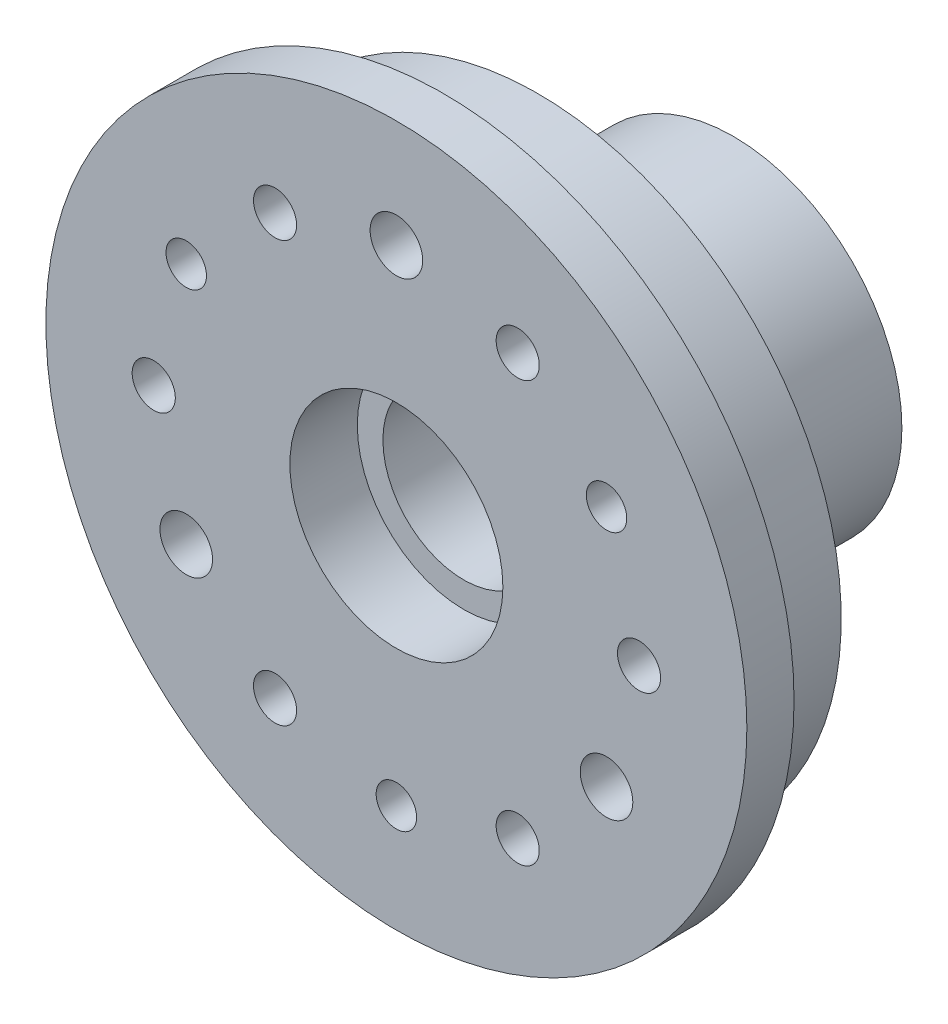
from build123d import *

# Parameters (mm, degrees)
SKETCH1_R           = 25
BOSS_EXTRUDE1_DEPTH = 20
SKETCH2_R           = 1.95
CUT_EXTRUDE1_DEPTH  = 4
SKETCH4_R           = 1.5
CUT_EXTRUDE2_DEPTH  = 21
SKETCH6_R           = 7.9
CUT_EXTRUDE3_DEPTH  = 21
BOSS_EXTRUDE4_START = -6
SKETCH7_R           = 7.9
SKETCH7_R_2         = 6
BOSS_EXTRUDE4_DEPTH = 9
SKETCH9_R           = 26
SKETCH9_R_2         = 25
BOSS_EXTRUDE6_DEPTH = 3.5
SKETCH10_R          = 25
SKETCH10_R_2        = 22.5
CUT_EXTRUDE5_DEPTH  = 16.5
SKETCH11_R          = 22.5
SKETCH11_R_2        = 12.5
CUT_EXTRUDE6_DEPTH  = 9.5
SKETCH12_R          = 3
CUT_EXTRUDE7_DEPTH  = 5
CIRPATTERN2_COUNT   = 3
SKETCH13_R          = 1.6
CUT_EXTRUDE8_DEPTH  = 21
CIRPATTERN3_COUNT   = 6
SKETCH15_R          = 12.5
SKETCH15_R_2        = 7.9
BOSS_EXTRUDE7_DEPTH = 5


with BuildPart() as part:
    # Sketch1 → Boss-Extrude1 (new body)
    with BuildSketch(Plane.XY):
        Circle(SKETCH1_R)
    extrude(amount=BOSS_EXTRUDE1_DEPTH)

    # Sketch2 → Cut-Extrude1 (cut)
    with BuildSketch(Plane.XY.offset(20)):
        with Locations((0, 18)):
            Circle(SKETCH2_R)
        with Locations((15.588457268, -9)):
            Circle(SKETCH2_R)
        with Locations((-15.588457268, -9)):
            Circle(SKETCH2_R)
    extrude(amount=-CUT_EXTRUDE1_DEPTH, mode=Mode.SUBTRACT)

    # Sketch4 → Cut-Extrude2 (cut, through all)
    with BuildSketch(Plane.XY.offset(20)):
        with Locations((15.588457268, 9)):
            Circle(SKETCH4_R)
        with Locations((0, -18)):
            Circle(SKETCH4_R)
        with Locations((-15.588457268, 9)):
            Circle(SKETCH4_R)
    extrude(amount=-CUT_EXTRUDE2_DEPTH, mode=Mode.SUBTRACT)

    # Sketch6 → Cut-Extrude3 (cut, through all)
    with BuildSketch(Plane.XY.offset(20)):
        Circle(SKETCH6_R)
    extrude(amount=-CUT_EXTRUDE3_DEPTH, mode=Mode.SUBTRACT)

    # Sketch7 → Boss-Extrude4 (add)
    with BuildSketch(Plane(origin=(0, 0, 0), x_dir=(-1, 0, 0), z_dir=(0, 0, -1)).offset(BOSS_EXTRUDE4_START)):
        Circle(SKETCH7_R)
        Circle(SKETCH7_R_2, mode=Mode.SUBTRACT)
    extrude(amount=-BOSS_EXTRUDE4_DEPTH)

    # Sketch9 → Boss-Extrude6 (add)
    with BuildSketch(Plane.XY.offset(20)):
        Circle(SKETCH9_R)
        Circle(SKETCH9_R_2, mode=Mode.SUBTRACT)
    extrude(amount=-BOSS_EXTRUDE6_DEPTH)

    # Sketch10 → Cut-Extrude5 (cut)
    with BuildSketch(Plane(origin=(0, 0, 0), x_dir=(-1, 0, 0), z_dir=(0, 0, -1))):
        Circle(SKETCH10_R)
        Circle(SKETCH10_R_2, mode=Mode.SUBTRACT)
    extrude(amount=-CUT_EXTRUDE5_DEPTH, mode=Mode.SUBTRACT)

    # Sketch11 → Cut-Extrude6 (cut)
    with BuildSketch(Plane(origin=(0, 0, 0), x_dir=(-1, 0, 0), z_dir=(0, 0, -1))):
        Circle(SKETCH11_R)
        Circle(SKETCH11_R_2, mode=Mode.SUBTRACT)
    extrude(amount=-CUT_EXTRUDE6_DEPTH, mode=Mode.SUBTRACT)

    # Sketch12 → Cut-Extrude7 (cut)
    with BuildSketch(Plane(origin=(0, 0, 9.5), x_dir=(-1, 0, 0), z_dir=(0, 0, -1))):
        with Locations((-15.588457268, 9)):
            Circle(SKETCH12_R)
    cut_extrude7 = extrude(amount=-CUT_EXTRUDE7_DEPTH, mode=Mode.SUBTRACT)

    # CirPattern2: Cut-Extrude7 ×3 about axis
    cirpattern2_axis = Axis((0, 0, 0), (0, 0, 1))
    for i in range(1, CIRPATTERN2_COUNT):
        add(cut_extrude7.rotate(cirpattern2_axis, i * 360 / CIRPATTERN2_COUNT), mode=Mode.SUBTRACT)

    # Sketch13 → Cut-Extrude8 (cut, through all)
    with BuildSketch(Plane.XY.offset(20)):
        with Locations((-9, 15.588457268)):
            Circle(SKETCH13_R)
    cut_extrude8 = extrude(amount=-CUT_EXTRUDE8_DEPTH, mode=Mode.SUBTRACT)

    # CirPattern3: Cut-Extrude8 ×6 about axis
    cirpattern3_axis = Axis((0, 0, 0), (0, 0, 1))
    for i in range(1, CIRPATTERN3_COUNT):
        add(cut_extrude8.rotate(cirpattern3_axis, i * 360 / CIRPATTERN3_COUNT), mode=Mode.SUBTRACT)

    # Sketch15 → Boss-Extrude7 (add)
    with BuildSketch(Plane(origin=(0, 0, 0), x_dir=(-1, 0, 0), z_dir=(0, 0, -1))):
        Circle(SKETCH15_R)
        Circle(SKETCH15_R_2, mode=Mode.SUBTRACT)
    extrude(amount=BOSS_EXTRUDE7_DEPTH)


solid = part.part
